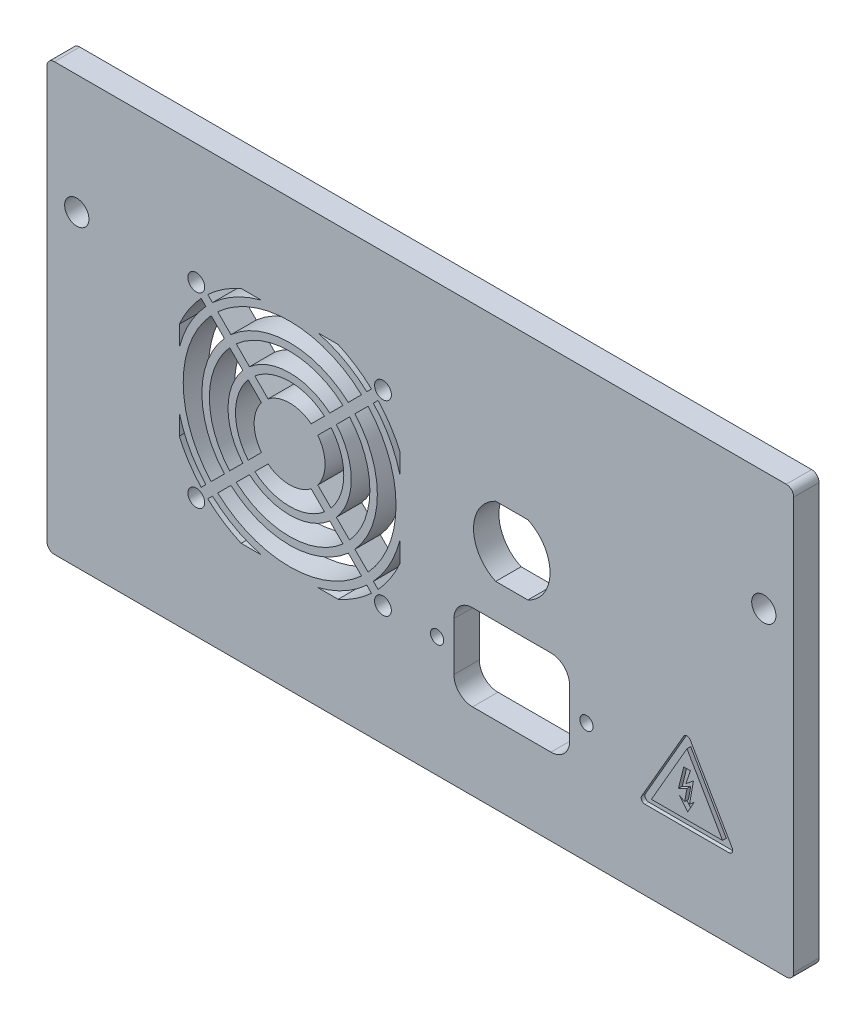
from build123d import *

# Parameters (mm, degrees)
SKETCH1_W           = 200
SKETCH1_H           = 114.3
BOSS_EXTRUDE1_DEPTH = 6.8
SKETCH2_R           = 3.25
CUT_EXTRUDE1_DEPTH  = 6.8
FILLET1_R           = 2
SKETCH3_R           = 1.775
SKETCH3_W           = 31
SKETCH3_H           = 23
CUT_EXTRUDE2_DEPTH  = 6.8
FILLET2_R           = 5
SKETCH4_R           = 28.5
SKETCH4_R_2         = 23.5
SKETCH4_R_3         = 21.5
SKETCH4_R_4         = 16.5
SKETCH4_R_5         = 14.5
SKETCH4_R_6         = 9.5
SKETCH4_R_7         = 2.25
CUT_EXTRUDE3_DEPTH  = 116.379211732
BOSS_EXTRUDE7_DEPTH = 6.8
CUT_EXTRUDE6_DEPTH  = 1


with BuildPart() as part:
    # Sketch1 → Boss-Extrude1 (new body)
    with BuildSketch(Plane.XY):
        Rectangle(SKETCH1_W, SKETCH1_H)
    extrude(amount=BOSS_EXTRUDE1_DEPTH)

    # Sketch2 → Cut-Extrude1 (cut)
    with BuildSketch(Plane.XY.offset(6.8)):
        with Locations((-92, 25.25)):
            Circle(SKETCH2_R)
        with Locations((92, 25.25)):
            Circle(SKETCH2_R)
    extrude(amount=-CUT_EXTRUDE1_DEPTH, mode=Mode.SUBTRACT)

    # Fillet1
    fillet1_edges = [part.edges().sort_by_distance(p)[0] for p in [
        (-100, 57.15, 3.4),
        (100, 57.15, 3.4),
        (100, -57.15, 3.4),
        (-100, -57.15, 3.4),
    ]]
    fillet(fillet1_edges, radius=FILLET1_R)

    # Sketch3 → Cut-Extrude2 (cut)
    with BuildSketch(Plane.XY.offset(6.8)):
        with Locations((4.5, -25)):
            Circle(SKETCH3_R)
        with Locations((44.5, -25)):
            Circle(SKETCH3_R)
        with Locations((24.5, -25)):
            Rectangle(SKETCH3_W, SKETCH3_H)
        with BuildLine():
            Line((20.190417654, 14.3), (28.809582346, 14.3))
            ThreePointArc((28.809582346, 14.3), (34.75, 5), (28.809582346, -4.3))
            Line((28.809582346, -4.3), (20.190417654, -4.3))
            ThreePointArc((20.190417654, -4.3), (14.25, 5), (20.190417654, 14.3))
        make_face()
    extrude(amount=-CUT_EXTRUDE2_DEPTH, mode=Mode.SUBTRACT)

    # Fillet2
    fillet2_edges = [part.edges().sort_by_distance(p)[0] for p in [
        (40, -13.5, 3.4),
        (40, -36.5, 3.4),
        (9, -36.5, 3.4),
        (9, -13.5, 3.4),
    ]]
    fillet(fillet2_edges, radius=FILLET2_R)

    # Sketch4 → Cut-Extrude3 (cut, through all)
    with BuildSketch(Plane.XY.offset(6.8)):
        with Locations((-35, 0)):
            Circle(SKETCH4_R)
        with Locations((-35, 0)):
            Circle(SKETCH4_R_2, mode=Mode.SUBTRACT)
        with Locations((-35, 0)):
            Circle(SKETCH4_R_3)
        with Locations((-35, 0)):
            Circle(SKETCH4_R_4, mode=Mode.SUBTRACT)
        with Locations((-35, 0)):
            Circle(SKETCH4_R_5)
        with Locations((-35, 0)):
            Circle(SKETCH4_R_6, mode=Mode.SUBTRACT)
        with BuildLine():
            Line((-22.009073716, 29.55), (-27.447020455, 29.55))
            ThreePointArc((-27.447020455, 29.55), (-13.433243174, 21.566756826), (-5.45, 7.552979545))
            Line((-5.45, 7.552979545), (-5.45, 12.990926284))
            ThreePointArc((-5.45, 12.990926284), (-12.174940682, 22.825059318), (-22.009073716, 29.55))
        make_face()
        with BuildLine():
            ThreePointArc((-47.990926284, 29.55), (-57.825059318, 22.825059318), (-64.55, 12.990926284))
            Line((-64.55, 12.990926284), (-64.55, 7.552979545))
            ThreePointArc((-64.55, 7.552979545), (-56.566756826, 21.566756826), (-42.552979545, 29.55))
            Line((-42.552979545, 29.55), (-47.990926284, 29.55))
        make_face()
        with BuildLine():
            ThreePointArc((-42.552979545, -29.55), (-56.566756826, -21.566756826), (-64.55, -7.552979545))
            Line((-64.55, -7.552979545), (-64.55, -12.990926284))
            ThreePointArc((-64.55, -12.990926284), (-57.825059318, -22.825059318), (-47.990926284, -29.55))
            Line((-47.990926284, -29.55), (-42.552979545, -29.55))
        make_face()
        with BuildLine():
            ThreePointArc((-5.45, -7.552979545), (-13.433243174, -21.566756826), (-27.447020455, -29.55))
            Line((-27.447020455, -29.55), (-22.009073716, -29.55))
            ThreePointArc((-22.009073716, -29.55), (-12.174940682, -22.825059318), (-5.45, -12.990926284))
            Line((-5.45, -12.990926284), (-5.45, -7.552979545))
        make_face()
        with Locations((-10, -25)):
            Circle(SKETCH4_R_7)
        with Locations((-60, -25)):
            Circle(SKETCH4_R_7)
        with Locations((-60, 25)):
            Circle(SKETCH4_R_7)
        with Locations((-10, 25)):
            Circle(SKETCH4_R_7)
    extrude(amount=-CUT_EXTRUDE3_DEPTH, mode=Mode.SUBTRACT)


with BuildPart() as cut_extrude3_piece_1:
    # of the separate pieces the step leaves, piece 1, a body of its own (cut_extrude3_pieces)
    add(part.part.solids().sort_by_distance((98, -57.15, 0))[0])



with BuildPart() as cut_extrude3_piece_2:
    # of the separate pieces the step leaves, piece 2, a body of its own (cut_extrude3_pieces)
    add(part.part.solids().sort_by_distance((-25.5, 0, 0))[0])


with BuildPart() as cut_extrude3_piece_3:
    # of the separate pieces the step leaves, piece 3, a body of its own (cut_extrude3_pieces)
    add(part.part.solids().sort_by_distance((-11.5, 0, 0))[0])


with BuildPart() as cut_extrude3_piece_4:
    # of the separate pieces the step leaves, piece 4, a body of its own (cut_extrude3_pieces)
    add(part.part.solids().sort_by_distance((-18.5, 0, 0))[0])


with BuildPart() as cut_extrude3_piece_1_1:
    add(cut_extrude3_piece_1.part)

    add(cut_extrude3_piece_2.part)  # Boss-Extrude7 merges Cut-Extrude3 piece 2

    add(cut_extrude3_piece_3.part)  # Boss-Extrude7 merges Cut-Extrude3 piece 3

    add(cut_extrude3_piece_4.part)  # Boss-Extrude7 merges Cut-Extrude3 piece 4
    # Sketch9 → Boss-Extrude7 (add)
    with BuildSketch(Plane.XY.offset(6.8)):
        Polygon((-31.982233047, 1.25), (-10.843604319, 22.388628728), (-12.611371272, 24.156395681), (-33.75, 3.017766953), (-33.75, 1.25), align=None)
        Polygon((-10.923846691, -22.308386356), (-31.982233047, -1.25), (-33.75, -1.25), (-33.75, -3.017766953), (-12.691613644, -24.076153309), align=None)
        Polygon((-36.25, 1.25), (-36.25, 3.017766953), (-57.308386356, 24.076153309), (-59.076153309, 22.308386356), (-38.017766953, 1.25), align=None)
        Polygon((-57.388628728, -24.156395681), (-36.25, -3.017766953), (-36.25, -1.25), (-38.017766953, -1.25), (-59.156395681, -22.388628728), align=None)
    extrude(amount=-BOSS_EXTRUDE7_DEPTH)

    # Sketch6 → Cut-Extrude6 (cut)
    with BuildSketch(Plane.XY.offset(6.8)):
        with BuildLine():
            Line((83.545946103, -34.5), (72.287615854, -15))
            ThreePointArc((72.287615854, -15), (71.42159045, -14.5), (70.555565047, -15))
            Line((70.555565047, -15), (59.297234797, -34.5))
            ThreePointArc((59.297234797, -34.5), (59.297234797, -35.5), (60.163260201, -36))
            Line((60.163260201, -36), (82.6799207, -36))
            ThreePointArc((82.6799207, -36), (83.545946103, -35.5), (83.545946103, -34.5))
        make_face()
        Polygon((61.895311009, -34), (80.947869892, -34), (71.42159045, -17.5), align=None, mode=Mode.SUBTRACT)
        Polygon((69.142579413, -27.8405455), (70.551015324, -22.149276649), (72.347394106, -22.149276649), (71.107138719, -25.764726734), (73.151026627, -24.109810005), (72.107844017, -29.983919065), (73.346390955, -28.98107931), (71.626753961, -32.031548417), (69.423161567, -29.310024263), (70.811409093, -30.092619241), (71.42159045, -26.709391164), align=None)
    extrude(amount=-CUT_EXTRUDE6_DEPTH, mode=Mode.SUBTRACT)


solid = cut_extrude3_piece_1_1.part
